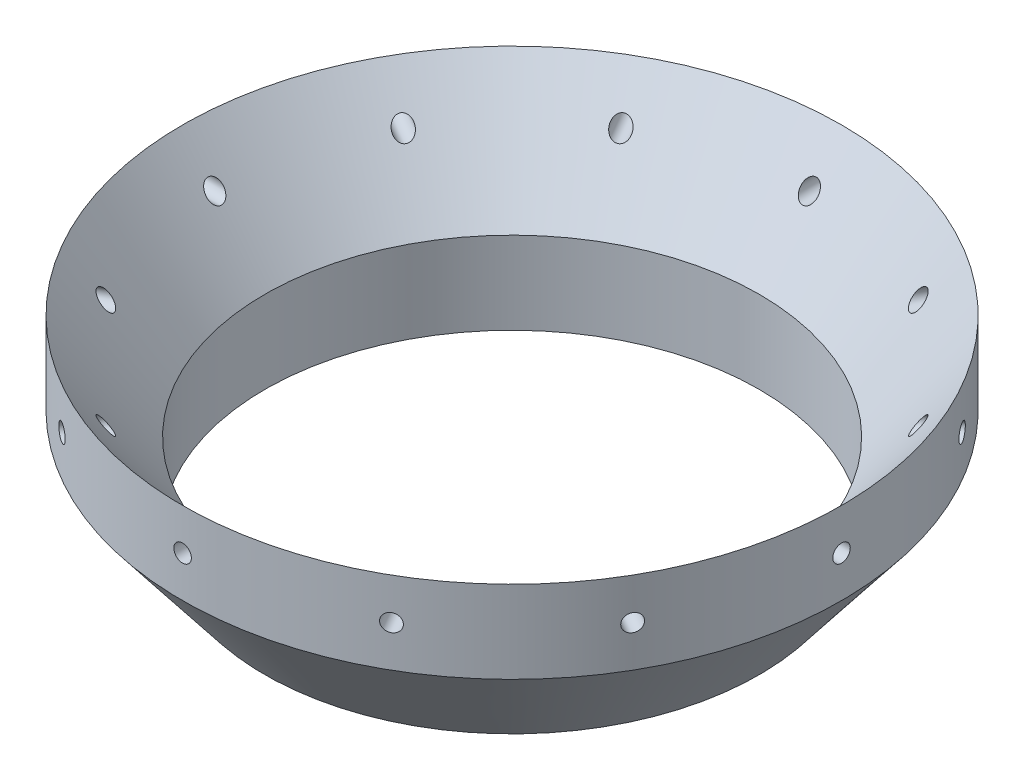
from build123d import *

# Parameters (mm, degrees)
SKETCH2_R          = 2.0193
CUT_EXTRUDE1_DEPTH = 267.514272105
CIRPATTERN1_COUNT  = 12


with BuildPart() as part:
    # Sketch1 → Revolve1 (revolve)
    with BuildSketch(Plane.XY):
        Polygon((-57.15, 200.321978871), (-57.15, 219.371978871), (-76.2, 243.755978871), (-76.2, 224.705978871), align=None)
    revolve(axis=Axis((0, 0, 0), (0, 1, 0)))

    # Sketch2 → Cut-Extrude1 (cut, through all)
    with BuildSketch(Plane.XY):
        with Locations((0, 234.230978871)):
            Circle(SKETCH2_R)
    cut_extrude1 = extrude(amount=-CUT_EXTRUDE1_DEPTH, mode=Mode.SUBTRACT)

    # CirPattern1: Cut-Extrude1 ×12 about axis
    cirpattern1_axis = Axis((0, 235.80346447, 0), (0, -1, 0))
    for i in range(1, CIRPATTERN1_COUNT):
        add(cut_extrude1.rotate(cirpattern1_axis, i * 360 / CIRPATTERN1_COUNT), mode=Mode.SUBTRACT)


solid = part.part
